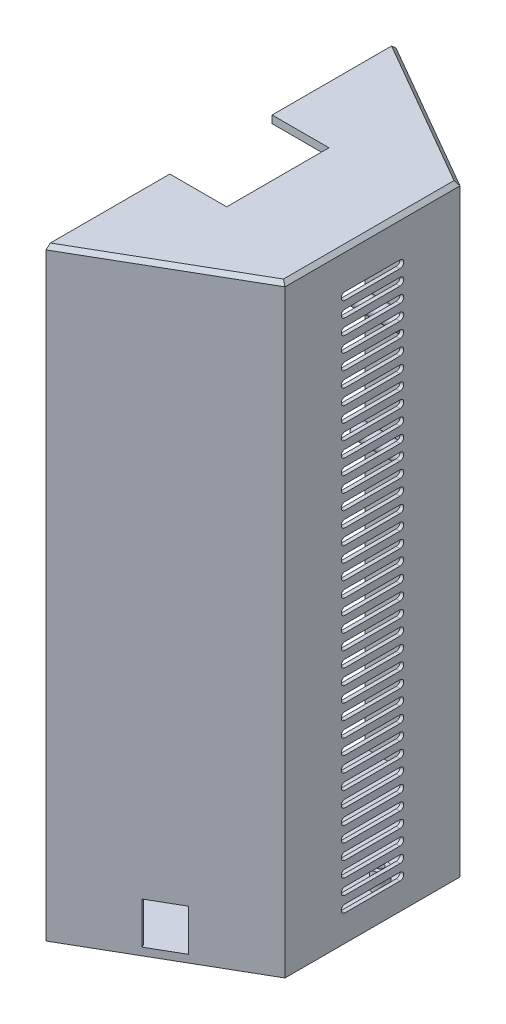
from build123d import *

# Parameters (mm, degrees)
BOSS_EXTRUDE5_DEPTH  = 155
BOSS_EXTRUDE6_DEPTH  = 2
BOSS_EXTRUDE7_DEPTH  = 155
CUT_EXTRUDE1_DEPTH   = 2
LPATTERN1_COUNT      = 36
LPATTERN1_PITCH      = 4
BOSS_EXTRUDE10_DEPTH = 2
CHAMFER2_SIZE        = 1
SKETCH13_W           = 30
SKETCH13_H           = 27
CUT_EXTRUDE2_DEPTH   = 10
SKETCH15_R           = 2
SKETCH15_R_2         = 0.9
BOSS_EXTRUDE11_DEPTH = 13
SKETCH16_R           = 2
SKETCH16_R_2         = 0.9
BOSS_EXTRUDE12_DEPTH = 5
SKETCH17_R           = 1.3
CUT_EXTRUDE3_DEPTH   = 5
SKETCH18_W           = 9
SKETCH18_H           = 11
CUT_EXTRUDE4_DEPTH   = 10


with BuildPart() as part:
    # Sketch4 → Boss-Extrude5 (new body)
    with BuildSketch(Plane(origin=(0, 0, 0), x_dir=(1, 0, 0), z_dir=(0, 1, 0))):
        Polygon((0, 46.188021535), (0, 45.033320997), (39, 22.516660498), (39, -22.516660498), (0, -45.033320997), (0, -46.188021535), (40, -23.094010768), (40, 23.094010768), align=None)
    extrude(amount=BOSS_EXTRUDE5_DEPTH)

    # Sketch5 → Boss-Extrude6 (add)
    with BuildSketch(Plane.XZ):
        Polygon((0, 46.188021535), (40, 23.094010768), (40, -23.094010768), (0, -46.188021535), align=None)
    extrude(amount=BOSS_EXTRUDE6_DEPTH)

    # Sketch6 → Boss-Extrude7 (add)
    with BuildSketch(Plane(origin=(0, 0, 0), x_dir=(1, 0, 0), z_dir=(0, 1, 0))):
        Polygon((0, -45.033320997), (0, -38.033320997), (12.124355653, -38.033320997), align=None)
        Polygon((0, 45.033320997), (0, 38.033320997), (12.124355653, 38.033320997), align=None)
    extrude(amount=BOSS_EXTRUDE7_DEPTH)

    # Sketch11 → Cut-Extrude1 (cut)
    with BuildSketch(Plane.ZY.offset(-39)):
        with BuildLine():
            Line((0, 147), (-7.25, 147))
            ThreePointArc((-7.25, 147), (-8.25, 146), (-7.25, 145))
            Line((-7.25, 145), (0, 145))
            Line((0, 145), (7.25, 145))
            ThreePointArc((7.25, 145), (8.25, 146), (7.25, 147))
            Line((7.25, 147), (0, 147))
        make_face()
    cut_extrude1 = extrude(amount=-CUT_EXTRUDE1_DEPTH, mode=Mode.SUBTRACT)

    # LPattern1: Cut-Extrude1 ×36
    with Locations(*[(0, -i * LPATTERN1_PITCH, 0) for i in range(1, LPATTERN1_COUNT)]):
        add(cut_extrude1, mode=Mode.SUBTRACT)

    # Sketch12 → Boss-Extrude10 (add)
    with BuildSketch(Plane(origin=(0, 155, 0), x_dir=(1, 0, 0), z_dir=(0, 1, 0))):
        Polygon((0, 46.188021535), (40, 23.094010768), (40, -23.094010768), (0, -46.188021535), align=None)
    extrude(amount=BOSS_EXTRUDE10_DEPTH)

    # Chamfer2
    chamfer2_edges = [part.edges().sort_by_distance(p)[0] for p in [
        (20, 157, 34.641016151),
        (40, 157, 0),
        (20, 157, -34.641016151),
    ]]
    chamfer(chamfer2_edges, length=CHAMFER2_SIZE)

    # Sketch13 → Cut-Extrude2 (cut)
    with BuildSketch(Plane(origin=(0, 157, 0), x_dir=(1, 0, 0), z_dir=(0, 1, 0))):
        Rectangle(SKETCH13_W, SKETCH13_H)
    extrude(amount=-CUT_EXTRUDE2_DEPTH, mode=Mode.SUBTRACT)

    # Sketch15 → Boss-Extrude11 (add)
    with BuildSketch(Plane.ZY.offset(-39)):
        with Locations((-10, 130)):
            Circle(SKETCH15_R)
        with Locations((-10, 130)):
            Circle(SKETCH15_R_2, mode=Mode.SUBTRACT)
        with Locations((10, 130)):
            Circle(SKETCH15_R)
        with Locations((10, 130)):
            Circle(SKETCH15_R_2, mode=Mode.SUBTRACT)
        with Locations((-10, 100)):
            Circle(SKETCH15_R)
        with Locations((-10, 100)):
            Circle(SKETCH15_R_2, mode=Mode.SUBTRACT)
        with Locations((10, 100)):
            Circle(SKETCH15_R)
        with Locations((10, 100)):
            Circle(SKETCH15_R_2, mode=Mode.SUBTRACT)
    extrude(amount=BOSS_EXTRUDE11_DEPTH)

    # Sketch16 → Boss-Extrude12 (add)
    with BuildSketch(Plane(origin=(0, 0, 0), x_dir=(1, 0, 0), z_dir=(0, 1, 0))):
        with Locations((34, 8.033320997)):
            Circle(SKETCH16_R)
        with Locations((34, 8.033320997)):
            Circle(SKETCH16_R_2, mode=Mode.SUBTRACT)
        with Locations((14, 8.033320997)):
            Circle(SKETCH16_R)
        with Locations((14, 8.033320997)):
            Circle(SKETCH16_R_2, mode=Mode.SUBTRACT)
    extrude(amount=BOSS_EXTRUDE12_DEPTH)

    # Sketch17 → Cut-Extrude3 (cut)
    with BuildSketch(Plane.ZY):
        with Locations((-41.188021535, 132)):
            Circle(SKETCH17_R)
        with Locations((-41.188021535, 78)):
            Circle(SKETCH17_R)
        with Locations((-41.188021535, 23)):
            Circle(SKETCH17_R)
        with Locations((41.188021535, 132)):
            Circle(SKETCH17_R)
        with Locations((41.188021535, 78)):
            Circle(SKETCH17_R)
        with Locations((41.188021535, 23)):
            Circle(SKETCH17_R)
    extrude(amount=-CUT_EXTRUDE3_DEPTH, mode=Mode.SUBTRACT)

    # Sketch18 → Cut-Extrude4 (cut)
    with BuildSketch(Plane(origin=(19.5, 0, 33.774990748), x_dir=(-0.866025404, 0, 0.5), z_dir=(-0.5, 0, -0.866025404))):
        with Locations((0.016660498, 5.5)):
            Rectangle(SKETCH18_W, SKETCH18_H)
    extrude(amount=-CUT_EXTRUDE4_DEPTH, mode=Mode.SUBTRACT)


solid = part.part
